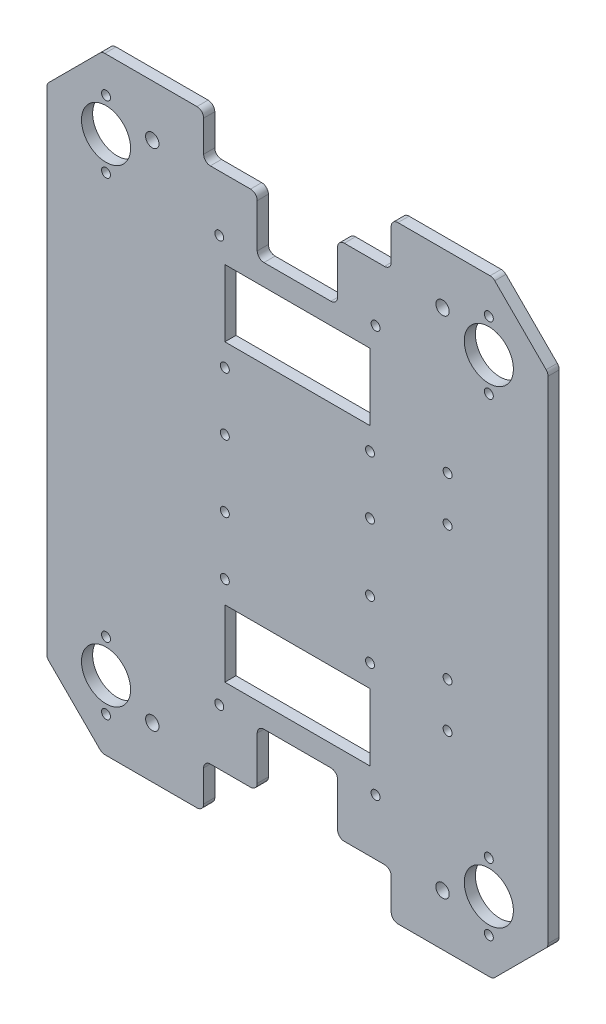
from build123d import *

# Parameters (mm, degrees)
BASE_DEPTH                = 5
ESQUISSE3_R               = 2
ESQUISSE3_W               = 65
ESQUISSE3_H               = 30
ENL_V_MAT_EXTRU_1_DEPTH   = 6
CONG_1_R                  = 3
PER_AGE_POUR_BILLES_REACH = 7
ESQUISSE6_R               = 2
ESQUISSE6_R_2             = 11
PER_AGE_POUR_PROFIL_REACH = 7
ESQUISSE8_R               = 3
ESQUISSE13_R              = 2
ENL_V_MAT_EXTRU_4_DEPTH   = 10
ESQUISSE14_R              = 2
ENL_V_MAT_EXTRU_5_DEPTH   = 10


with BuildPart() as part:
    # Esquisse1 → Base (new body)
    with BuildSketch(Plane.XY):
        Polygon((0, 0), (-175, 0), (-199.748737342, 24.748737342), (-199.748737342, 247.248737342), (-175, 271.997474683), (0, 271.997474683), (24.748737342, 247.248737342), (24.748737342, 24.748737342), align=None)
    extrude(amount=BASE_DEPTH)

    # Esquisse3 → Enlèv. mat.-Extru.1 (cut, through all)
    with BuildSketch(Plane(origin=(0, 0, 0), x_dir=(-1, 0, 0), z_dir=(0, 0, -1))):
        with Locations((52.5, 45)):
            Circle(ESQUISSE3_R)
        with Locations((122.5, 45)):
            Circle(ESQUISSE3_R)
        with Locations((122.5, 226.997474683)):
            Circle(ESQUISSE3_R)
        with Locations((52.5, 226.997474683)):
            Circle(ESQUISSE3_R)
        Polygon((129.5, 0), (129.5, 20), (105.5, 20), (105.5, 45.5), (69.5, 45.5), (69.5, 20), (45.5, 20), (45.5, 0), align=None)
        Polygon((45.5, 271.997474683), (129.5, 271.997474683), (129.5, 251.997474683), (105.5, 251.997474683), (105.5, 226.497474683), (69.5, 226.497474683), (69.5, 251.997474683), (45.5, 251.997474683), align=None)
        with Locations((87.5, 201.997474683)):
            Rectangle(ESQUISSE3_W, ESQUISSE3_H)
        with Locations((87.5, 70)):
            Rectangle(ESQUISSE3_W, ESQUISSE3_H)
    extrude(amount=-ENL_V_MAT_EXTRU_1_DEPTH, mode=Mode.SUBTRACT)

    # Congé1
    cong_1_edges = [part.edges().sort_by_distance(p)[0] for p in [
        (0, 0, 2.5),
        (-175, 0, 2.5),
        (-199.748737342, 24.748737342, 2.5),
        (-199.748737342, 247.248737342, 2.5),
        (-175, 271.997474683, 2.5),
        (0, 271.997474683, 2.5),
        (24.748737342, 247.248737342, 2.5),
        (24.748737342, 24.748737342, 2.5),
        (-45.5, 251.997474683, 2.5),
        (-45.5, 271.997474683, 2.5),
        (-129.5, 271.997474683, 2.5),
        (-129.5, 251.997474683, 2.5),
        (-105.5, 251.997474683, 2.5),
        (-105.5, 226.497474683, 2.5),
        (-69.5, 226.497474683, 2.5),
        (-69.5, 251.997474683, 2.5),
        (-129.5, 0, 2.5),
        (-45.5, 0, 2.5),
        (-45.5, 20, 2.5),
        (-69.5, 20, 2.5),
        (-69.5, 45.5, 2.5),
        (-105.5, 45.5, 2.5),
        (-105.5, 20, 2.5),
        (-129.5, 20, 2.5),
    ]]
    fillet(cong_1_edges, radius=CONG_1_R)

    # Esquisse6 → Perçage pour billes (cut, up to next)
    with BuildSketch(Plane.XY.offset(5), mode=Mode.PRIVATE) as per_age_pour_billes_sk1:
        with Locations((-1.784271247, 16)):
            Circle(ESQUISSE6_R)
    per_age_pour_billes_tool1 = extrude(per_age_pour_billes_sk1.sketch, amount=-PER_AGE_POUR_BILLES_REACH, mode=Mode.PRIVATE) & part.part
    add(per_age_pour_billes_tool1.solids().sort_by_distance((-1.784271, 16, 5))[0], mode=Mode.SUBTRACT)
    # Esquisse6 → Perçage pour billes (cut, up to next)
    with BuildSketch(Plane.XY.offset(5), mode=Mode.PRIVATE) as per_age_pour_billes_sk2:
        with Locations((-1.784271247, 46)):
            Circle(ESQUISSE6_R)
    per_age_pour_billes_tool2 = extrude(per_age_pour_billes_sk2.sketch, amount=-PER_AGE_POUR_BILLES_REACH, mode=Mode.PRIVATE) & part.part
    add(per_age_pour_billes_tool2.solids().sort_by_distance((-1.784271, 46, 5))[0], mode=Mode.SUBTRACT)
    # Esquisse6 → Perçage pour billes (cut, up to next)
    with BuildSketch(Plane.XY.offset(5), mode=Mode.PRIVATE) as per_age_pour_billes_sk3:
        with Locations((-1.784271247, 225.997474683)):
            Circle(ESQUISSE6_R)
    per_age_pour_billes_tool3 = extrude(per_age_pour_billes_sk3.sketch, amount=-PER_AGE_POUR_BILLES_REACH, mode=Mode.PRIVATE) & part.part
    add(per_age_pour_billes_tool3.solids().sort_by_distance((-1.784271, 225.997475, 5))[0], mode=Mode.SUBTRACT)
    # Esquisse6 → Perçage pour billes (cut, up to next)
    with BuildSketch(Plane.XY.offset(5), mode=Mode.PRIVATE) as per_age_pour_billes_sk4:
        with Locations((-1.784271247, 255.997474683)):
            Circle(ESQUISSE6_R)
    per_age_pour_billes_tool4 = extrude(per_age_pour_billes_sk4.sketch, amount=-PER_AGE_POUR_BILLES_REACH, mode=Mode.PRIVATE) & part.part
    add(per_age_pour_billes_tool4.solids().sort_by_distance((-1.784271, 255.997475, 5))[0], mode=Mode.SUBTRACT)
    # Esquisse6 → Perçage pour billes (cut, up to next)
    with BuildSketch(Plane.XY.offset(5), mode=Mode.PRIVATE) as per_age_pour_billes_sk5:
        with Locations((-1.784271247, 240.997474683)):
            Circle(ESQUISSE6_R_2)
    per_age_pour_billes_tool5 = extrude(per_age_pour_billes_sk5.sketch, amount=-PER_AGE_POUR_BILLES_REACH, mode=Mode.PRIVATE) & part.part
    add(per_age_pour_billes_tool5.solids().sort_by_distance((-1.784271, 240.997475, 5))[0], mode=Mode.SUBTRACT)
    # Esquisse6 → Perçage pour billes (cut, up to next)
    with BuildSketch(Plane.XY.offset(5), mode=Mode.PRIVATE) as per_age_pour_billes_sk6:
        with Locations((-1.784271247, 31)):
            Circle(ESQUISSE6_R_2)
    per_age_pour_billes_tool6 = extrude(per_age_pour_billes_sk6.sketch, amount=-PER_AGE_POUR_BILLES_REACH, mode=Mode.PRIVATE) & part.part
    add(per_age_pour_billes_tool6.solids().sort_by_distance((-1.784271, 31, 5))[0], mode=Mode.SUBTRACT)
    # Esquisse6 → Perçage pour billes (cut, up to next)
    with BuildSketch(Plane.XY.offset(5), mode=Mode.PRIVATE) as per_age_pour_billes_sk7:
        with Locations((-173.215728753, 16)):
            Circle(ESQUISSE6_R)
    per_age_pour_billes_tool7 = extrude(per_age_pour_billes_sk7.sketch, amount=-PER_AGE_POUR_BILLES_REACH, mode=Mode.PRIVATE) & part.part
    add(per_age_pour_billes_tool7.solids().sort_by_distance((-173.215729, 16, 5))[0], mode=Mode.SUBTRACT)
    # Esquisse6 → Perçage pour billes (cut, up to next)
    with BuildSketch(Plane.XY.offset(5), mode=Mode.PRIVATE) as per_age_pour_billes_sk8:
        with Locations((-173.215728753, 46)):
            Circle(ESQUISSE6_R)
    per_age_pour_billes_tool8 = extrude(per_age_pour_billes_sk8.sketch, amount=-PER_AGE_POUR_BILLES_REACH, mode=Mode.PRIVATE) & part.part
    add(per_age_pour_billes_tool8.solids().sort_by_distance((-173.215729, 46, 5))[0], mode=Mode.SUBTRACT)
    # Esquisse6 → Perçage pour billes (cut, up to next)
    with BuildSketch(Plane.XY.offset(5), mode=Mode.PRIVATE) as per_age_pour_billes_sk9:
        with Locations((-173.215728753, 31)):
            Circle(ESQUISSE6_R_2)
    per_age_pour_billes_tool9 = extrude(per_age_pour_billes_sk9.sketch, amount=-PER_AGE_POUR_BILLES_REACH, mode=Mode.PRIVATE) & part.part
    add(per_age_pour_billes_tool9.solids().sort_by_distance((-173.215729, 31, 5))[0], mode=Mode.SUBTRACT)
    # Esquisse6 → Perçage pour billes (cut, up to next)
    with BuildSketch(Plane.XY.offset(5), mode=Mode.PRIVATE) as per_age_pour_billes_sk10:
        with Locations((-173.215728753, 225.997474683)):
            Circle(ESQUISSE6_R)
    per_age_pour_billes_tool10 = extrude(per_age_pour_billes_sk10.sketch, amount=-PER_AGE_POUR_BILLES_REACH, mode=Mode.PRIVATE) & part.part
    add(per_age_pour_billes_tool10.solids().sort_by_distance((-173.215729, 225.997475, 5))[0], mode=Mode.SUBTRACT)
    # Esquisse6 → Perçage pour billes (cut, up to next)
    with BuildSketch(Plane.XY.offset(5), mode=Mode.PRIVATE) as per_age_pour_billes_sk11:
        with Locations((-173.215728753, 255.997474683)):
            Circle(ESQUISSE6_R)
    per_age_pour_billes_tool11 = extrude(per_age_pour_billes_sk11.sketch, amount=-PER_AGE_POUR_BILLES_REACH, mode=Mode.PRIVATE) & part.part
    add(per_age_pour_billes_tool11.solids().sort_by_distance((-173.215729, 255.997475, 5))[0], mode=Mode.SUBTRACT)
    # Esquisse6 → Perçage pour billes (cut, up to next)
    with BuildSketch(Plane.XY.offset(5), mode=Mode.PRIVATE) as per_age_pour_billes_sk12:
        with Locations((-173.215728753, 240.997474683)):
            Circle(ESQUISSE6_R_2)
    per_age_pour_billes_tool12 = extrude(per_age_pour_billes_sk12.sketch, amount=-PER_AGE_POUR_BILLES_REACH, mode=Mode.PRIVATE) & part.part
    add(per_age_pour_billes_tool12.solids().sort_by_distance((-173.215729, 240.997475, 5))[0], mode=Mode.SUBTRACT)

    # Esquisse8 → Perçage pour profilé (cut, up to next)
    with BuildSketch(Plane.XY.offset(5), mode=Mode.PRIVATE) as per_age_pour_profil_sk1:
        with Locations((-152.5, 23)):
            Circle(ESQUISSE8_R)
    per_age_pour_profil_tool1 = extrude(per_age_pour_profil_sk1.sketch, amount=-PER_AGE_POUR_PROFIL_REACH, mode=Mode.PRIVATE) & part.part
    add(per_age_pour_profil_tool1.solids().sort_by_distance((-152.5, 23, 5))[0], mode=Mode.SUBTRACT)
    # Esquisse8 → Perçage pour profilé (cut, up to next)
    with BuildSketch(Plane.XY.offset(5), mode=Mode.PRIVATE) as per_age_pour_profil_sk2:
        with Locations((-152.5, 248.997474683)):
            Circle(ESQUISSE8_R)
    per_age_pour_profil_tool2 = extrude(per_age_pour_profil_sk2.sketch, amount=-PER_AGE_POUR_PROFIL_REACH, mode=Mode.PRIVATE) & part.part
    add(per_age_pour_profil_tool2.solids().sort_by_distance((-152.5, 248.997475, 5))[0], mode=Mode.SUBTRACT)
    # Esquisse8 → Perçage pour profilé (cut, up to next)
    with BuildSketch(Plane.XY.offset(5), mode=Mode.PRIVATE) as per_age_pour_profil_sk3:
        with Locations((-22.5, 248.997474683)):
            Circle(ESQUISSE8_R)
    per_age_pour_profil_tool3 = extrude(per_age_pour_profil_sk3.sketch, amount=-PER_AGE_POUR_PROFIL_REACH, mode=Mode.PRIVATE) & part.part
    add(per_age_pour_profil_tool3.solids().sort_by_distance((-22.5, 248.997475, 5))[0], mode=Mode.SUBTRACT)
    # Esquisse8 → Perçage pour profilé (cut, up to next)
    with BuildSketch(Plane.XY.offset(5), mode=Mode.PRIVATE) as per_age_pour_profil_sk4:
        with Locations((-22.5, 23)):
            Circle(ESQUISSE8_R)
    per_age_pour_profil_tool4 = extrude(per_age_pour_profil_sk4.sketch, amount=-PER_AGE_POUR_PROFIL_REACH, mode=Mode.PRIVATE) & part.part
    add(per_age_pour_profil_tool4.solids().sort_by_distance((-22.5, 23, 5))[0], mode=Mode.SUBTRACT)

    # Esquisse13 → Enlèv. mat.-Extru.4 (cut)
    with BuildSketch(Plane.XY.offset(5)):
        with Locations((-20.251262658, 185.998737342)):
            Circle(ESQUISSE13_R)
        with Locations((-20.251262658, 165.998737342)):
            Circle(ESQUISSE13_R)
        with Locations((-20.251262658, 105.998737342)):
            Circle(ESQUISSE13_R)
        with Locations((-20.251262658, 85.998737342)):
            Circle(ESQUISSE13_R)
    extrude(amount=-ENL_V_MAT_EXTRU_4_DEPTH, mode=Mode.SUBTRACT)

    # Esquisse14 → Enlèv. mat.-Extru.5 (cut)
    with BuildSketch(Plane.XY.offset(5)):
        with Locations((-120, 176.997474683)):
            Circle(ESQUISSE14_R)
        with Locations((-55, 176.997474683)):
            Circle(ESQUISSE14_R)
        with Locations((-120, 150.997474683)):
            Circle(ESQUISSE14_R)
        with Locations((-55, 150.997474683)):
            Circle(ESQUISSE14_R)
        with Locations((-120, 121)):
            Circle(ESQUISSE14_R)
        with Locations((-55, 121)):
            Circle(ESQUISSE14_R)
        with Locations((-55, 95)):
            Circle(ESQUISSE14_R)
        with Locations((-120, 95)):
            Circle(ESQUISSE14_R)
    extrude(amount=-ENL_V_MAT_EXTRU_5_DEPTH, mode=Mode.SUBTRACT)


solid = part.part
